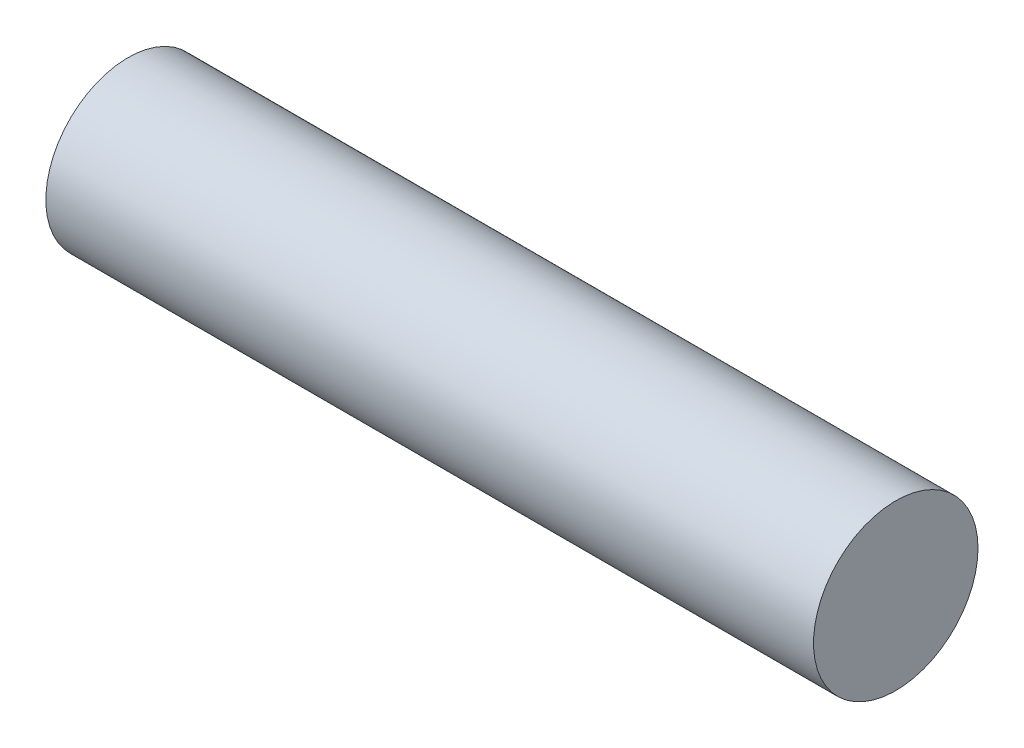
from build123d import *

# Parameters (mm, degrees)
SKETCH1_R           = 2.25
BOSS_EXTRUDE1_DEPTH = 21


with BuildPart() as part:
    # Sketch1 → Boss-Extrude1 (new body)
    with BuildSketch(Plane(origin=(0, 0, 0), x_dir=(0, 0, -1), z_dir=(1, 0, 0))):
        Circle(SKETCH1_R)
    extrude(amount=BOSS_EXTRUDE1_DEPTH)


solid = part.part
